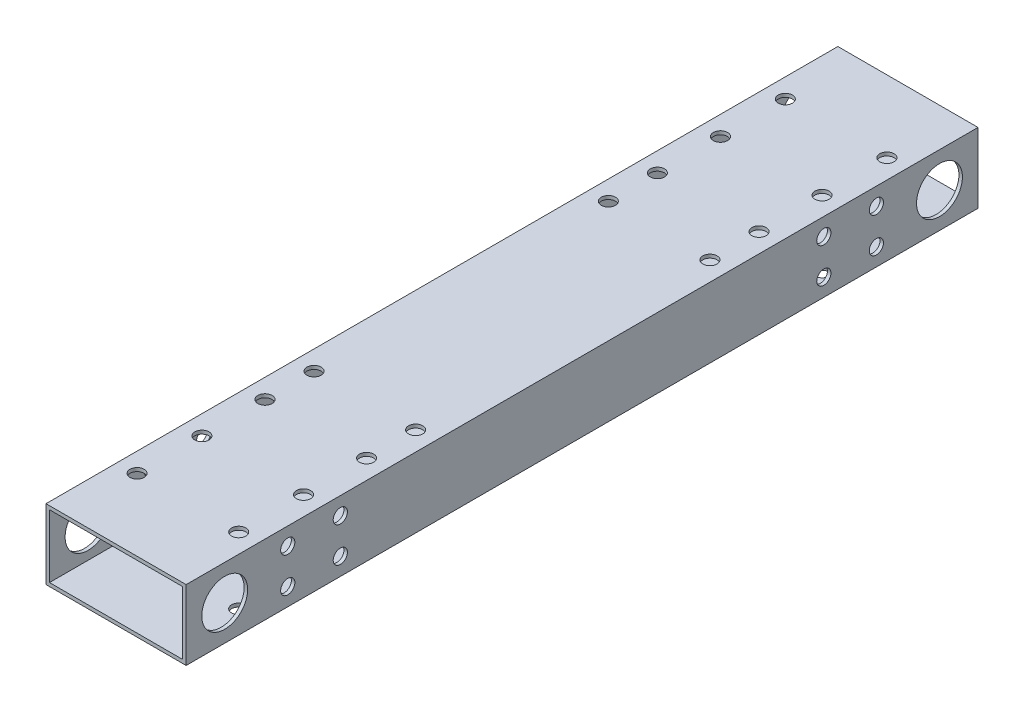
from build123d import *

# Parameters (mm, degrees)
SKETCH_1_W          = 40
SKETCH_1_H          = 20
SKETCH_1_W_2        = 38
SKETCH_1_H_2        = 18
EXTRUDE_1_DEPTH     = 113
SKETCH_2_R          = 6.55
CUT_EXTRUDE_1_DEPTH = 40
SKETCH_3_R          = 2.025
CUT_EXTRUDE_2_DEPTH = 30
SKETCH_4_R          = 2.025
CUT_EXTRUDE_3_DEPTH = 20
SKETCH_6_R          = 2.025
CUT_EXTRUDE_4_DEPTH = 30
SKETCH_9_R          = 3.75
CUT_EXTRUDE_5_DEPTH = 2
SKETCH_10_R         = 2.025
CUT_EXTRUDE_6_DEPTH = 50
SKETCH_11_R         = 3.75
SKETCH_11_R_2       = 2.025
EXTRUDE_2_DEPTH     = 1
SKETCH_13_R         = 2.025
CUT_EXTRUDE_8_DEPTH = 55


with BuildPart() as part:
    # 草图1 → 凸台-拉伸1 (new body, symmetric)
    with BuildSketch(Plane.XY):
        Rectangle(SKETCH_1_W, SKETCH_1_H)
        Rectangle(SKETCH_1_W_2, SKETCH_1_H_2, mode=Mode.SUBTRACT)
    extrude(amount=EXTRUDE_1_DEPTH, both=True)

    # 草图2 → 切除-拉伸1 (cut)
    with BuildSketch(Plane(origin=(20, 0, 0), x_dir=(0, 0, -1), z_dir=(1, 0, 0))):
        with Locations((102, 0)):
            Circle(SKETCH_2_R)
        with Locations((-102, 0)):
            Circle(SKETCH_2_R)
    extrude(amount=-CUT_EXTRUDE_1_DEPTH, mode=Mode.SUBTRACT)

    # 草图3 → 切除-拉伸2 (cut)
    with BuildSketch(Plane(origin=(0, 10, 0), x_dir=(1, 0, 0), z_dir=(0, 1, 0))):
        with Locations((-14.5, 92.5)):
            Circle(SKETCH_3_R)
        with Locations((14.5, 92.5)):
            Circle(SKETCH_3_R)
        with Locations((14.5, -92.5)):
            Circle(SKETCH_3_R)
        with Locations((-14.5, -92.5)):
            Circle(SKETCH_3_R)
    extrude(amount=-CUT_EXTRUDE_2_DEPTH, mode=Mode.SUBTRACT)

    # 草图4 → 切除-拉伸3 (cut)
    with BuildSketch(Plane(origin=(0, 10, 0), x_dir=(1, 0, 0), z_dir=(0, 1, 0))):
        with Locations((-14.5, 74)):
            Circle(SKETCH_4_R)
        with Locations((-14.5, 56)):
            Circle(SKETCH_4_R)
        with Locations((14.5, 56)):
            Circle(SKETCH_4_R)
        with Locations((14.5, 74)):
            Circle(SKETCH_4_R)
        with Locations((14.5, -74)):
            Circle(SKETCH_4_R)
        with Locations((14.5, -56)):
            Circle(SKETCH_4_R)
        with Locations((-14.5, -56)):
            Circle(SKETCH_4_R)
        with Locations((-14.5, -74)):
            Circle(SKETCH_4_R)
    extrude(amount=-CUT_EXTRUDE_3_DEPTH, mode=Mode.SUBTRACT)

    # 草图6 → 切除-拉伸4 (cut)
    with BuildSketch(Plane(origin=(0, 10, 0), x_dir=(1, 0, 0), z_dir=(0, 1, 0))):
        with Locations((-14.5, 42)):
            Circle(SKETCH_6_R)
        with Locations((14.5, 42)):
            Circle(SKETCH_6_R)
        with Locations((-14.5, -42)):
            Circle(SKETCH_6_R)
        with Locations((14.5, -42)):
            Circle(SKETCH_6_R)
    extrude(amount=-CUT_EXTRUDE_4_DEPTH, mode=Mode.SUBTRACT)

    # 草图9 → 切除-拉伸5 (cut)
    with BuildSketch(Plane.XZ.offset(10)):
        with Locations((-14.5, 74)):
            Circle(SKETCH_9_R)
        with Locations((14.5, 74)):
            Circle(SKETCH_9_R)
        with Locations((-14.5, 56)):
            Circle(SKETCH_9_R)
        with Locations((-14.5, 42)):
            Circle(SKETCH_9_R)
        with Locations((14.5, 42)):
            Circle(SKETCH_9_R)
        with Locations((14.5, 56)):
            Circle(SKETCH_9_R)
        with Locations((14.5, -56)):
            Circle(SKETCH_9_R)
        with Locations((14.5, -42)):
            Circle(SKETCH_9_R)
        with Locations((-14.5, -42)):
            Circle(SKETCH_9_R)
        with Locations((-14.5, -56)):
            Circle(SKETCH_9_R)
        with Locations((14.5, -74)):
            Circle(SKETCH_9_R)
        with Locations((-14.5, -74)):
            Circle(SKETCH_9_R)
    extrude(amount=-CUT_EXTRUDE_5_DEPTH, mode=Mode.SUBTRACT)

    # 草图10 → 切除-拉伸6 (cut)
    with BuildSketch(Plane.ZY.offset(20)):
        with Locations((84, 5)):
            Circle(SKETCH_10_R)
        with Locations((84, -5)):
            Circle(SKETCH_10_R)
        with Locations((-84, 5)):
            Circle(SKETCH_10_R)
        with Locations((-84, -5)):
            Circle(SKETCH_10_R)
    extrude(amount=-CUT_EXTRUDE_6_DEPTH, mode=Mode.SUBTRACT)

    # 草图11 → 凸台-拉伸2 (add)
    with BuildSketch(Plane.XZ.offset(10)):
        with Locations((14.5, -74)):
            Circle(SKETCH_11_R)
        with Locations((14.5, -74)):
            Circle(SKETCH_11_R_2, mode=Mode.SUBTRACT)
        with Locations((-14.5, -74)):
            Circle(SKETCH_11_R)
        with Locations((-14.5, -74)):
            Circle(SKETCH_11_R_2, mode=Mode.SUBTRACT)
        with Locations((-14.5, 74)):
            Circle(SKETCH_11_R)
        with Locations((-14.5, 74)):
            Circle(SKETCH_11_R_2, mode=Mode.SUBTRACT)
        with Locations((14.5, 74)):
            Circle(SKETCH_11_R)
        with Locations((14.5, 74)):
            Circle(SKETCH_11_R_2, mode=Mode.SUBTRACT)
    extrude(amount=-EXTRUDE_2_DEPTH)

    # 草图13 → 切除-拉伸8 (cut)
    with BuildSketch(Plane(origin=(20, 0, 0), x_dir=(0, 0, -1), z_dir=(1, 0, 0))):
        with Locations((-69, 5)):
            Circle(SKETCH_13_R)
        with Locations((-69, -5)):
            Circle(SKETCH_13_R)
        with Locations((69, -5)):
            Circle(SKETCH_13_R)
        with Locations((69, 5)):
            Circle(SKETCH_13_R)
    extrude(amount=-CUT_EXTRUDE_8_DEPTH, mode=Mode.SUBTRACT)


solid = part.part
